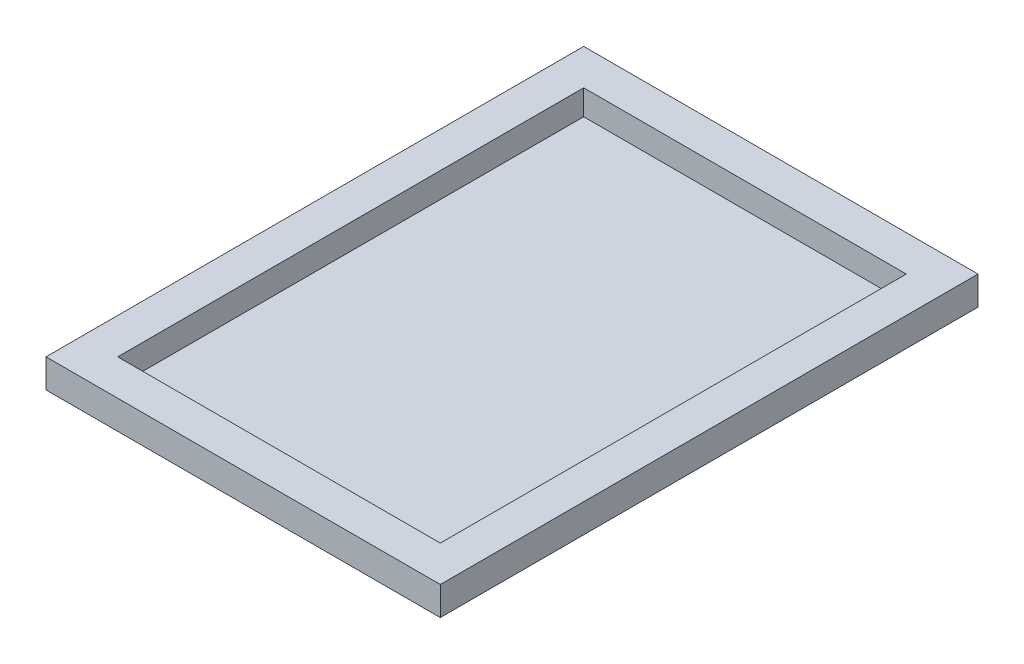
from build123d import *

# Parameters (mm, degrees)
SKICA1_W        = 110
SKICA1_H        = 150
SKICA1_W_2      = 90
SKICA1_H_2      = 130
VYSUNOUT1_DEPTH = 8
SKICA2_W        = 90
SKICA2_H        = 130
VYSUNOUT2_DEPTH = 1


with BuildPart() as part:
    # Skica1 → Vysunout1 (new body)
    with BuildSketch(Plane(origin=(0, 0, 0), x_dir=(1, 0, 0), z_dir=(0, 1, 0))):
        Rectangle(SKICA1_W, SKICA1_H)
        Rectangle(SKICA1_W_2, SKICA1_H_2, mode=Mode.SUBTRACT)
    extrude(amount=VYSUNOUT1_DEPTH)

    # Skica2 → Vysunout2 (add)
    with BuildSketch(Plane.XZ):
        Rectangle(SKICA2_W, SKICA2_H)
    extrude(amount=-VYSUNOUT2_DEPTH)


solid = part.part
